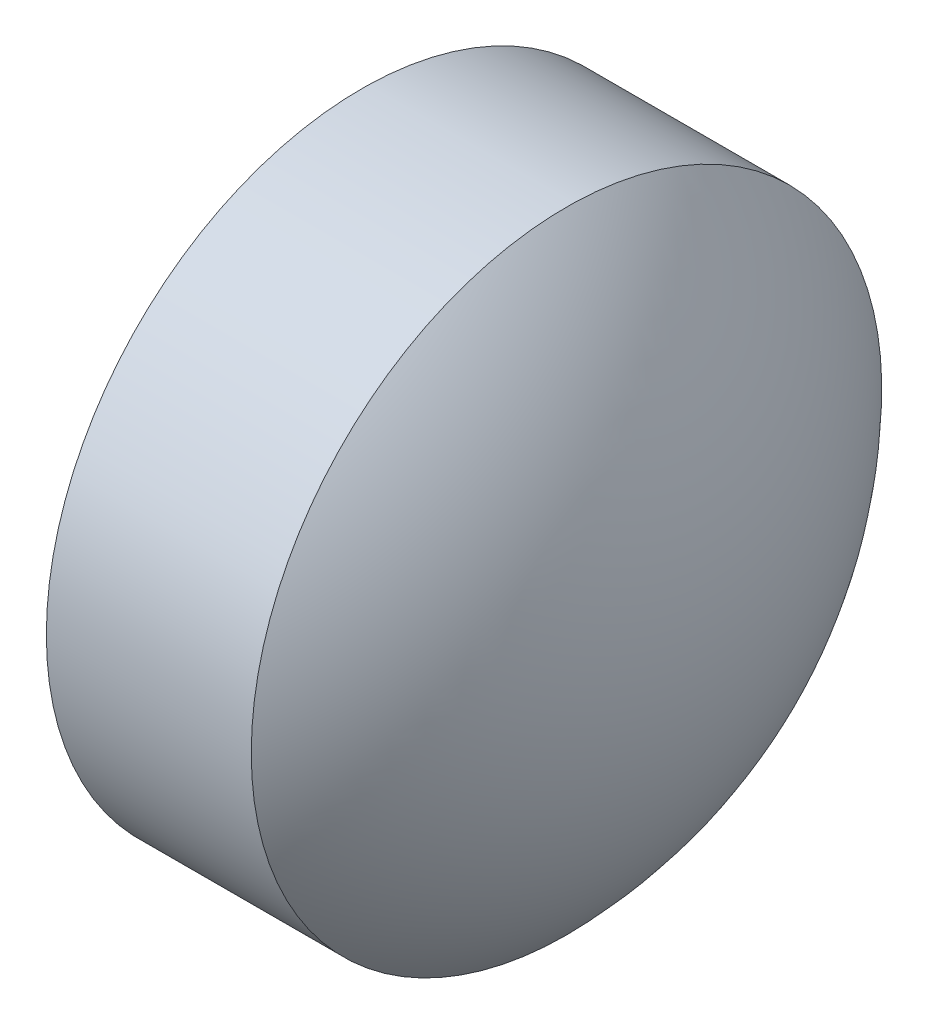
from build123d import *


with BuildPart() as part:
    # 草图1 → 旋转1 (revolve)
    with BuildSketch(Plane.XY, mode=Mode.PRIVATE) as revolve_1_sk:
        with BuildLine():
            Line((369.362026145, 55.67682588), (369.362026145, 57.67682588))
            Line((369.362026145, 57.67682588), (370.662026145, 57.67682588))
            ThreePointArc((370.662026145, 57.67682588), (371.261840719, 56.755725782), (371.472026145, 55.67682588))
            Line((371.472026145, 55.67682588), (369.362026145, 55.67682588))
        make_face()
    revolve(revolve_1_sk.sketch.rotate(Axis((368.933919451, 55.67682588, 0), (1, 0, 0)), 180), axis=Axis((368.933919451, 55.67682588, 0), (1, 0, 0)))  # turned: the seam where the file's is


solid = part.part
